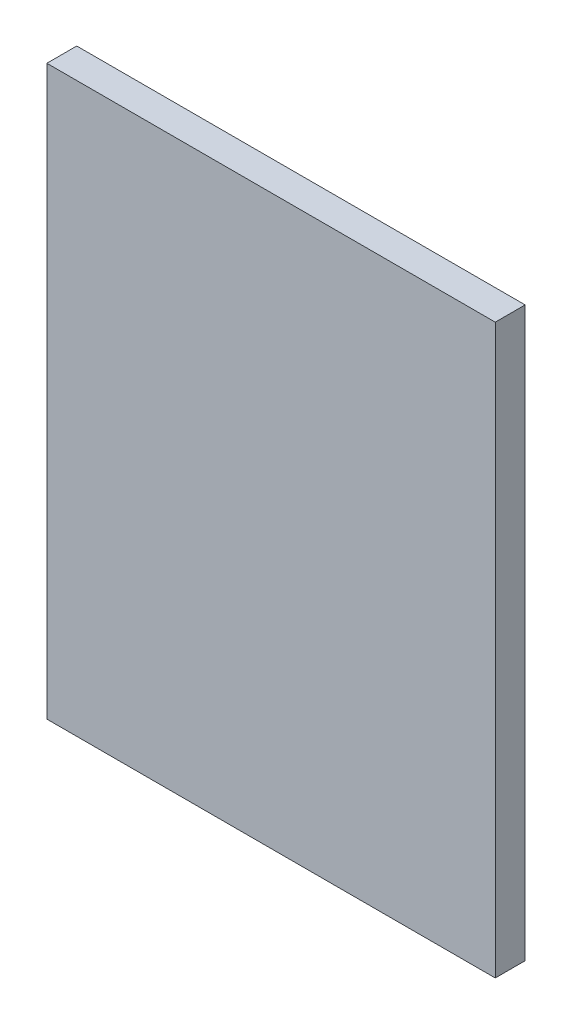
from build123d import *

# Parameters (mm, degrees)
SKETCH1_W           = 75
SKETCH1_H           = 95
BOSS_EXTRUDE1_DEPTH = 5


with BuildPart() as part:
    # Sketch1 → Boss-Extrude1 (new body)
    with BuildSketch(Plane.XY):
        with Locations((37.5, 47.5)):
            Rectangle(SKETCH1_W, SKETCH1_H)
    extrude(amount=BOSS_EXTRUDE1_DEPTH)


solid = part.part
